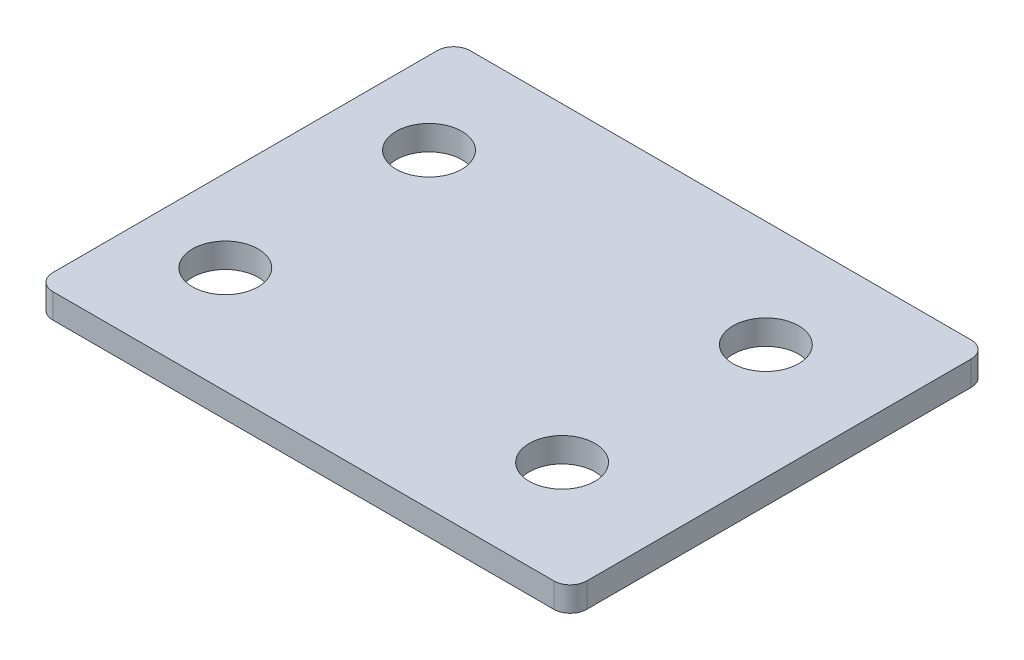
from build123d import *

# Parameters (mm, degrees)
SKETCH1_R           = 4
BOSS_EXTRUDE1_DEPTH = 3


with BuildPart() as part:
    # Sketch1 → Boss-Extrude1 (new body)
    with BuildSketch(Plane(origin=(0, 0, 0), x_dir=(1, 0, 0), z_dir=(0, 1, 0))):
        with BuildLine():
            Line((-30.5, -25.4), (30.5, -25.4))
            ThreePointArc((30.5, -25.4), (31.914213562, -24.814213562), (32.5, -23.4))
            Line((32.5, -23.4), (32.5, 23.4))
            ThreePointArc((32.5, 23.4), (31.914213562, 24.814213562), (30.5, 25.4))
            Line((30.5, 25.4), (-30.5, 25.4))
            ThreePointArc((-30.5, 25.4), (-31.914213562, 24.814213562), (-32.5, 23.4))
            Line((-32.5, 23.4), (-32.5, -23.4))
            ThreePointArc((-32.5, -23.4), (-31.914213562, -24.814213562), (-30.5, -25.4))
        make_face()
        with Locations((-22.5, 12.4)):
            Circle(SKETCH1_R, mode=Mode.SUBTRACT)
        with Locations((18.5, 12.4)):
            Circle(SKETCH1_R, mode=Mode.SUBTRACT)
        with Locations((-22.5, -12.4)):
            Circle(SKETCH1_R, mode=Mode.SUBTRACT)
        with Locations((18.5, -12.4)):
            Circle(SKETCH1_R, mode=Mode.SUBTRACT)
    extrude(amount=BOSS_EXTRUDE1_DEPTH)


solid = part.part
